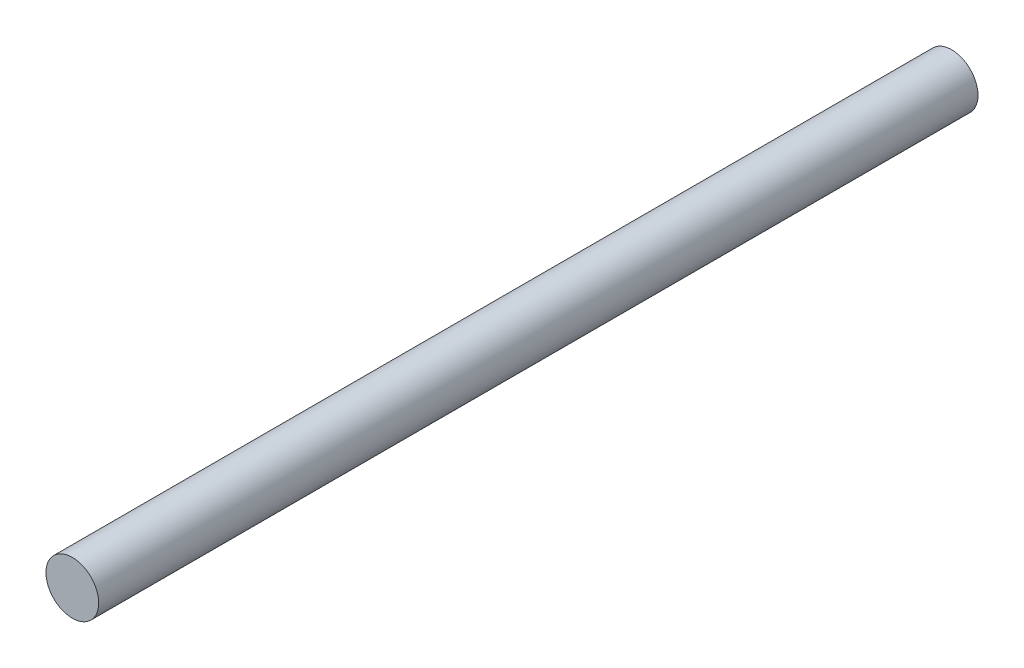
from build123d import *

# Parameters (mm, degrees)
SKETCH1_R           = 150
BOSS_EXTRUDE1_DEPTH = 5000


with BuildPart() as part:
    # Sketch1 → Boss-Extrude1 (new body)
    with BuildSketch(Plane.XY):
        Circle(SKETCH1_R)
    extrude(amount=BOSS_EXTRUDE1_DEPTH)


solid = part.part
